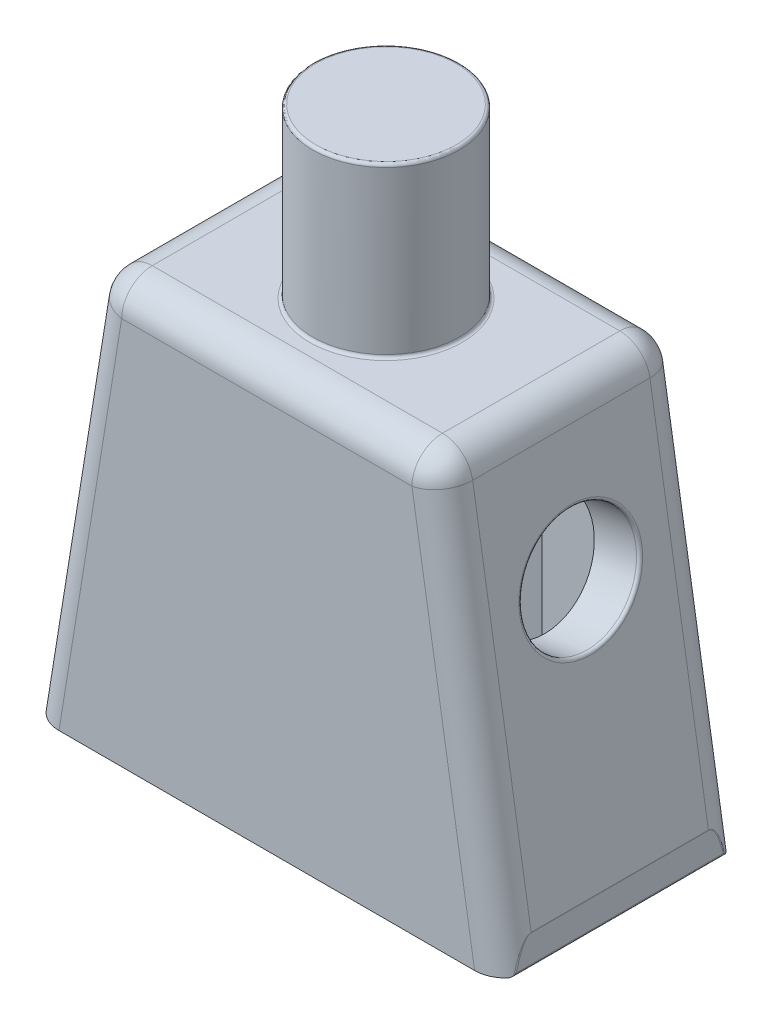
from build123d import *

# Parameters (mm, degrees)
SALIENTE_EXTRUIR1_DEPTH = 3.9
VACIADO1_T              = -1.5
CROQUIS2_R              = 1.9
CORTAR_EXTRUIR1_DEPTH   = 1.5
SALIENTE_EXTRUIR2_DEPTH = 12.2
CROQUIS4_R              = 2.4
SALIENTE_EXTRUIR3_DEPTH = 5.5
CROQUIS5_R              = 1.25
CORTAR_EXTRUIR2_DEPTH   = 4.25
REDONDEO1_R             = 1
REDONDEO2_R             = 0.1


with BuildPart() as part:
    # Croquis1 → Saliente-Extruir1 (new body, symmetric)
    with BuildSketch(Plane.XY):
        Polygon((7.65, 0), (-7.65, 0), (-7.65, 1), (-5.6, 13.7), (5.6, 13.7), (7.65, 1), align=None)
    extrude(amount=SALIENTE_EXTRUIR1_DEPTH, both=True)

    # Vaciado1
    vaciado1_openings = [part.faces().sort_by_distance(p)[0] for p in [
        (0, 0, 0),
    ]]
    offset(amount=VACIADO1_T, openings=vaciado1_openings, kind=Kind.INTERSECTION)

    # Croquis2 → Cortar-Extruir1 (cut)
    with BuildSketch(Plane(origin=(7.613054972, 1.228878952, 0), x_dir=(0, 0, -1), z_dir=(0.987221404, 0.159354636, 0))):
        with Locations((0, 7.780937034)):
            Circle(CROQUIS2_R)
    cortar_extruir1 = extrude(amount=-CORTAR_EXTRUIR1_DEPTH, mode=Mode.SUBTRACT)

    # Simetría1: Cortar-Extruir1 across plane
    add(cortar_extruir1.mirror(Plane(origin=(0, 0, 0), x_dir=(0, 0, 1), z_dir=(1, 0, 0))), mode=Mode.SUBTRACT)

    # Croquis3 → Saliente-Extruir2 (add)
    with BuildSketch(Plane.XZ):
        Polygon((1.5, 2.4), (1.5, 1.6), (2.7, 2.4), align=None)
        Polygon((-1.5, 1.6), (-2.7, 2.4), (-1.5, 2.4), align=None)
    saliente_extruir2 = extrude(amount=-SALIENTE_EXTRUIR2_DEPTH)

    # Simetría2: Saliente-Extruir2 across plane
    add(saliente_extruir2.mirror(Plane.XY))

    # Croquis4 → Saliente-Extruir3 (add)
    with BuildSketch(Plane(origin=(0, 13.7, 0), x_dir=(1, 0, 0), z_dir=(0, 1, 0))):
        Circle(CROQUIS4_R)
    extrude(amount=SALIENTE_EXTRUIR3_DEPTH)

    # Croquis5 → Cortar-Extruir2 (cut)
    with BuildSketch(Plane.XZ.offset(-12.2)):
        Circle(CROQUIS5_R)
    extrude(amount=-CORTAR_EXTRUIR2_DEPTH, mode=Mode.SUBTRACT)

    # Redondeo1
    redondeo1_edges = [part.edges().sort_by_distance(p)[0] for p in [
        (6.625, 7.35, -3.9),
        (-6.625, 7.35, -3.9),
        (-6.625, 7.35, 3.9),
        (6.625, 7.35, 3.9),
        (5.6, 13.7, 0),
        (0, 13.7, -3.9),
        (0, 13.7, 3.9),
        (-5.6, 13.7, 0),
    ]]
    fillet(redondeo1_edges, radius=REDONDEO1_R)

    # Redondeo2
    redondeo2_edges = [part.edges().sort_by_distance(p)[0] for p in [
        (-7.65, 0.566832693, 3.265088592),
        (-7.65, 0, 0),
        (-7.65, 0.566832693, -3.265088592),
        (-7.65, 1, 0),
        (7.65, 0.566832693, 3.265088592),
        (7.65, 1, 0),
        (7.65, 0.566832693, -3.265088592),
        (7.65, 0, 0),
        (-2.4, 13.7, 0),
        (-2.4, 19.2, 0),
        (-6.373126583, 8.910386534, 1.9),
        (6.373126583, 8.910386534, 1.9),
    ]]
    fillet(redondeo2_edges, radius=REDONDEO2_R)


solid = part.part
